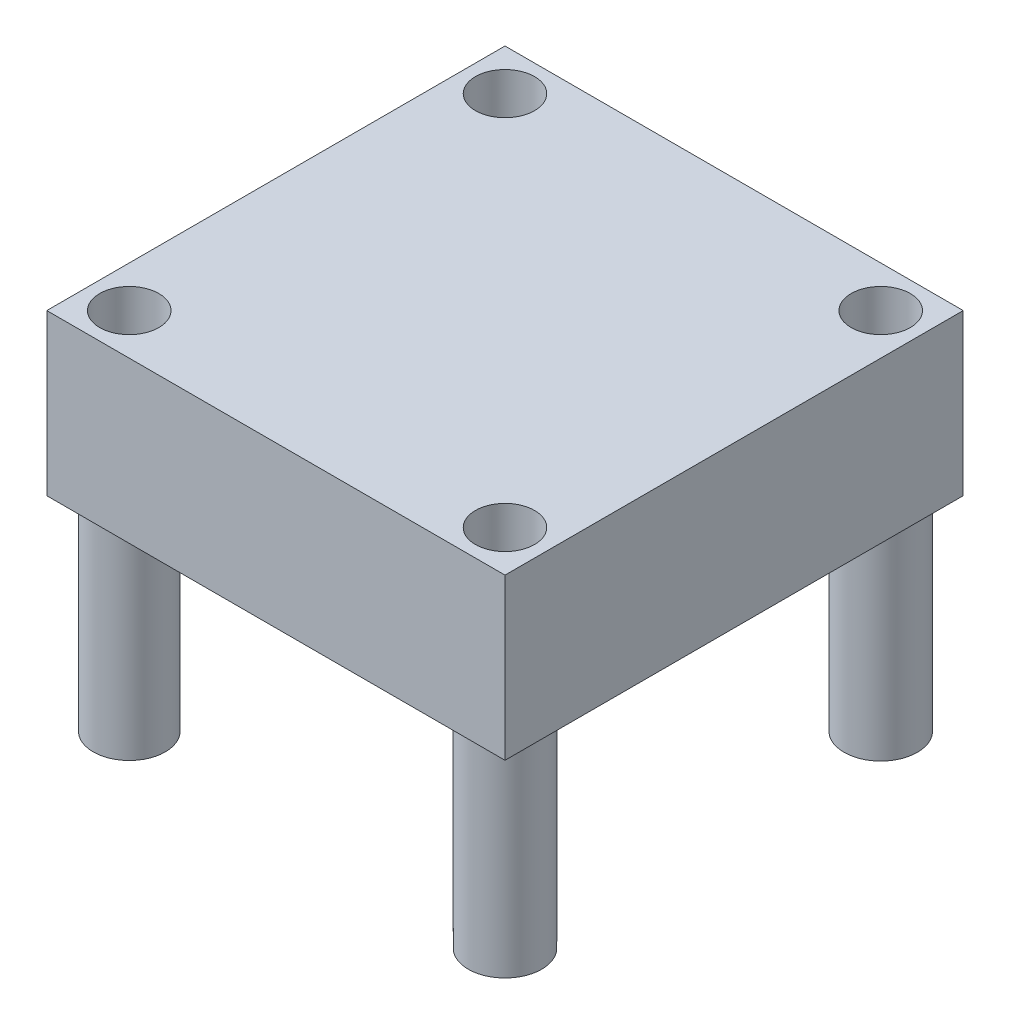
from build123d import *

# Parameters (mm, degrees)
SKETCH1_W           = 25.4
SKETCH1_H           = 25.4
BOSS_EXTRUDE1_DEPTH = 8.89
SKETCH2_R           = 1.9939
SKETCH2_R_2         = 2.032
BOSS_EXTRUDE2_DEPTH = 11.303
SKETCH3_R           = 1.6383
CUT_EXTRUDE1_DEPTH  = 21.193


with BuildPart() as part:
    # Sketch1 → Boss-Extrude1 (new body)
    with BuildSketch(Plane(origin=(0, 0, 0), x_dir=(1, 0, 0), z_dir=(0, 1, 0))):
        with Locations((-4.163944862, -1.223942607)):
            Rectangle(SKETCH1_W, SKETCH1_H)
    extrude(amount=BOSS_EXTRUDE1_DEPTH)

    # Sketch2 → Boss-Extrude2 (add)
    with BuildSketch(Plane.XZ):
        with Locations((-14.577944862, 11.637942607)):
            Circle(SKETCH2_R)
        with Locations((6.250055138, 11.637942607)):
            Circle(SKETCH2_R_2)
        with Locations((6.250055138, -9.190057393)):
            Circle(SKETCH2_R_2)
        with Locations((-14.577944862, -9.190057393)):
            Circle(SKETCH2_R_2)
    extrude(amount=BOSS_EXTRUDE2_DEPTH)

    # Sketch3 → Cut-Extrude1 (cut, through all)
    with BuildSketch(Plane.XZ.offset(11.303)):
        with Locations((-14.577944862, 11.637942607)):
            Circle(SKETCH3_R)
        with Locations((-14.577944862, -9.190057393)):
            Circle(SKETCH3_R)
        with Locations((6.250055138, -9.190057393)):
            Circle(SKETCH3_R)
        with Locations((6.250055138, 11.637942607)):
            Circle(SKETCH3_R)
    extrude(amount=-CUT_EXTRUDE1_DEPTH, mode=Mode.SUBTRACT)


solid = part.part
